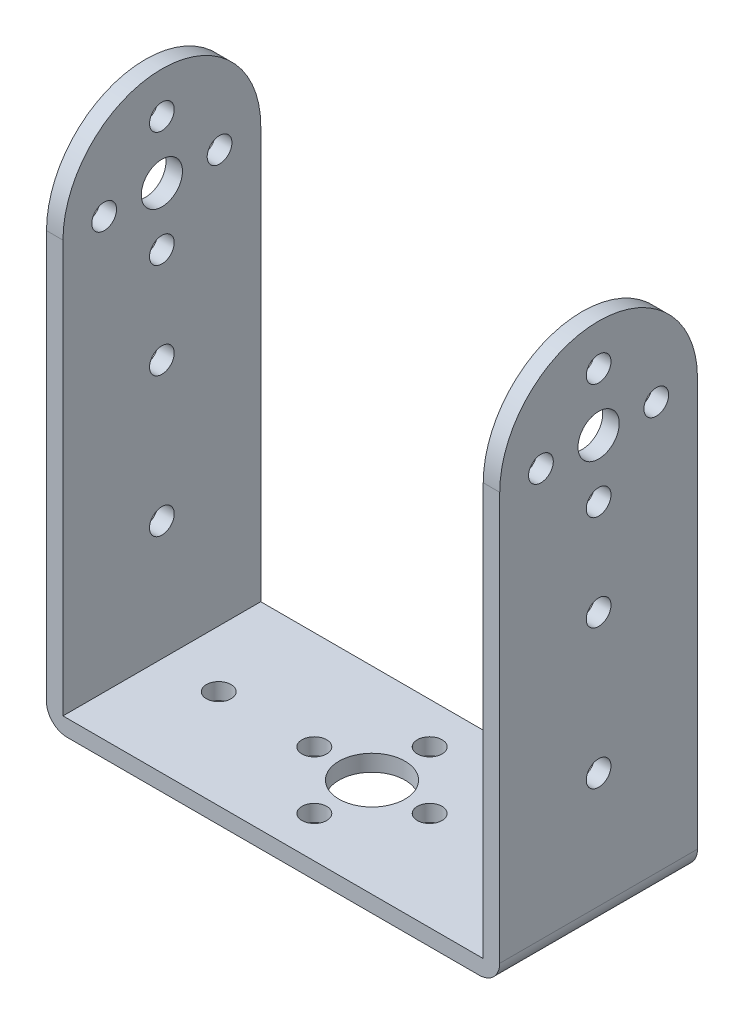
from build123d import *

# Parameters (mm, degrees)
SKETCH2_W           = 55
SKETCH2_H           = 24
SKETCH2_R           = 4
SKETCH2_R_2         = 1.5
BOSS_EXTRUDE1_DEPTH = 2
SKETCH5_R           = 2.5
SKETCH5_R_2         = 1.5
BOSS_EXTRUDE2_DEPTH = 2
FILLET1_R           = 2.5


with BuildPart() as part:
    # Sketch2 → Boss-Extrude1 (new body)
    with BuildSketch(Plane(origin=(0, 0, 0), x_dir=(1, 0, 0), z_dir=(0, 1, 0))):
        Rectangle(SKETCH2_W, SKETCH2_H)
        Circle(SKETCH2_R, mode=Mode.SUBTRACT)
        with Locations((0, 7)):
            Circle(SKETCH2_R_2, mode=Mode.SUBTRACT)
        with Locations((7, 0)):
            Circle(SKETCH2_R_2, mode=Mode.SUBTRACT)
        with Locations((0, -7)):
            Circle(SKETCH2_R_2, mode=Mode.SUBTRACT)
        with Locations((-7, 0)):
            Circle(SKETCH2_R_2, mode=Mode.SUBTRACT)
        with Locations((-18.6, 0)):
            Circle(SKETCH2_R_2, mode=Mode.SUBTRACT)
        with Locations((18.6, 0)):
            Circle(SKETCH2_R_2, mode=Mode.SUBTRACT)
    extrude(amount=BOSS_EXTRUDE1_DEPTH)

    # Sketch5 → Boss-Extrude2 (add)
    with BuildSketch(Plane.ZY.offset(27.5)):
        with BuildLine():
            Line((12, 0), (12, 52))
            ThreePointArc((12, 52), (0, 64), (-12, 52))
            Line((-12, 52), (-12, 0))
            Line((-12, 0), (12, 0))
        make_face()
        with Locations((0, 52)):
            Circle(SKETCH5_R, mode=Mode.SUBTRACT)
        with Locations((0, 59)):
            Circle(SKETCH5_R_2, mode=Mode.SUBTRACT)
        with Locations((7, 52)):
            Circle(SKETCH5_R_2, mode=Mode.SUBTRACT)
        with Locations((0, 45)):
            Circle(SKETCH5_R_2, mode=Mode.SUBTRACT)
        with Locations((-7, 52)):
            Circle(SKETCH5_R_2, mode=Mode.SUBTRACT)
        with Locations((0, 33.4)):
            Circle(SKETCH5_R_2, mode=Mode.SUBTRACT)
        with Locations((0, 16.5)):
            Circle(SKETCH5_R_2, mode=Mode.SUBTRACT)
    boss_extrude2 = extrude(amount=-BOSS_EXTRUDE2_DEPTH)

    # Mirror1: Boss-Extrude2 across plane
    add(boss_extrude2.mirror(Plane(origin=(0, 0, 0), x_dir=(0, 0, 1), z_dir=(1, 0, 0))))

    # Fillet1
    fillet1_edges = [part.edges().sort_by_distance(p)[0] for p in [
        (-27.5, 0, 0),
        (27.5, 0, 0),
    ]]
    fillet(fillet1_edges, radius=FILLET1_R)


solid = part.part
